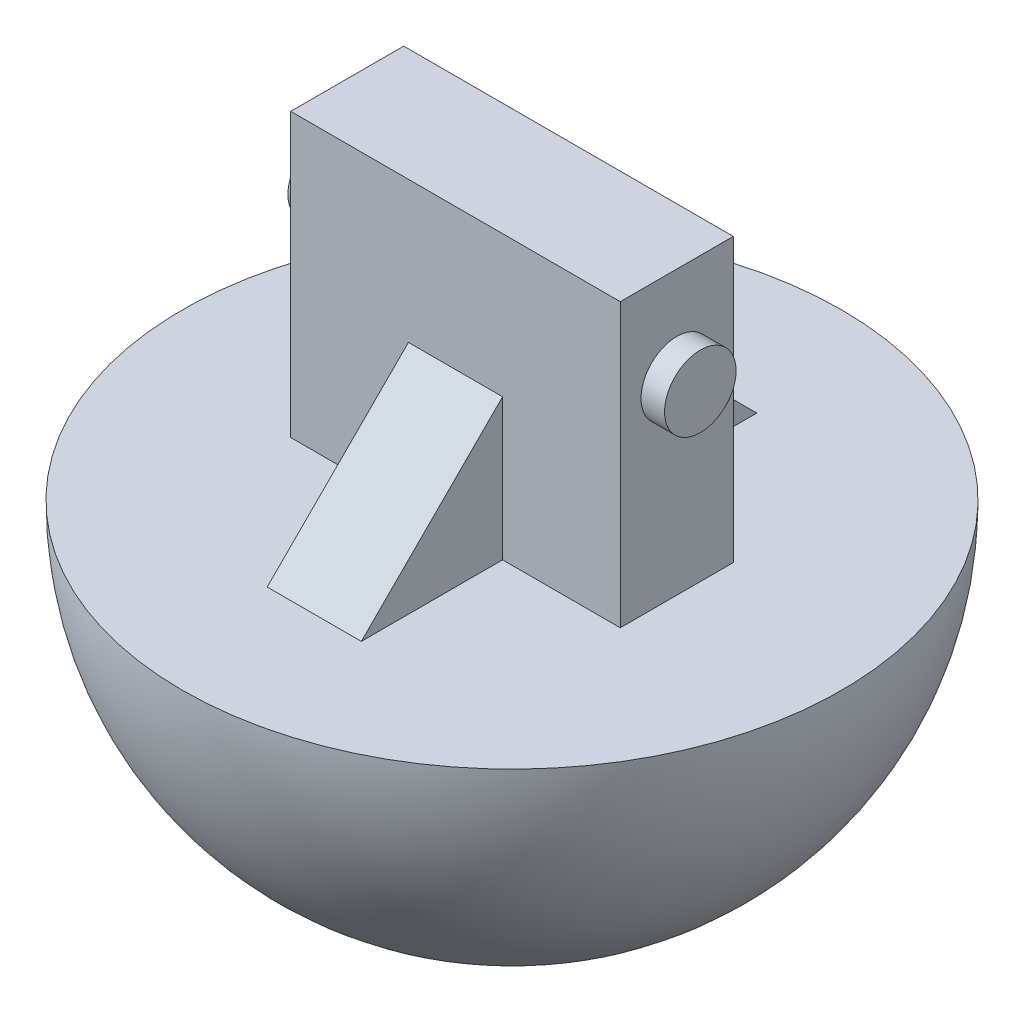
from build123d import *

# Parameters (mm, degrees)
SKETCH1_W           = 44.45
SKETCH1_H           = 38.1
BOSS_EXTRUDE1_DEPTH = 15.24
SKETCH2_R           = 4.826
BOSS_EXTRUDE2_DEPTH = 3.175
BOSS_EXTRUDE3_DEPTH = 6.35


with BuildPart() as part:
    # Sketch1 → Boss-Extrude1 (new body)
    with BuildSketch(Plane.XY):
        Rectangle(SKETCH1_W, SKETCH1_H)
    extrude(amount=BOSS_EXTRUDE1_DEPTH)

    # Sketch2 → Boss-Extrude2 (add)
    with BuildSketch(Plane(origin=(22.225, 0, 0), x_dir=(0, 0, -1), z_dir=(1, 0, 0))):
        with Locations((-7.62, 6.35)):
            Circle(SKETCH2_R)
    boss_extrude2 = extrude(amount=BOSS_EXTRUDE2_DEPTH)

    # Mirror1: Boss-Extrude2 across plane
    add(boss_extrude2.mirror(Plane(origin=(0, 0, 0), x_dir=(0, 0, 1), z_dir=(1, 0, 0))))

    # Sketch5 → Revolve1 (revolve)
    with BuildSketch(Plane(origin=(0, 0, 0), x_dir=(0, 0, -1), z_dir=(1, 0, 0))):
        with BuildLine():
            Line((-52.07, -19.05), (-7.62, -19.05))
            Line((-7.62, -19.05), (-7.62, -63.5))
            ThreePointArc((-7.62, -63.5), (-39.050896424, -50.480896424), (-52.07, -19.05))
        make_face()
    revolve(axis=Axis((0, -19.05, 7.62), (0, -1, 0)))

    # Sketch7 → Boss-Extrude3 (add, symmetric)
    with BuildSketch(Plane(origin=(0, 0, 0), x_dir=(0, 0, -1), z_dir=(1, 0, 0))):
        Polygon((-15.24, 0), (-15.24, -19.05), (-34.29, -19.05), align=None)
    boss_extrude3 = extrude(amount=BOSS_EXTRUDE3_DEPTH, both=True)

    # Mirror3: Boss-Extrude3 across plane
    add(boss_extrude3.mirror(Plane.XY.offset(7.62)))


solid = part.part
